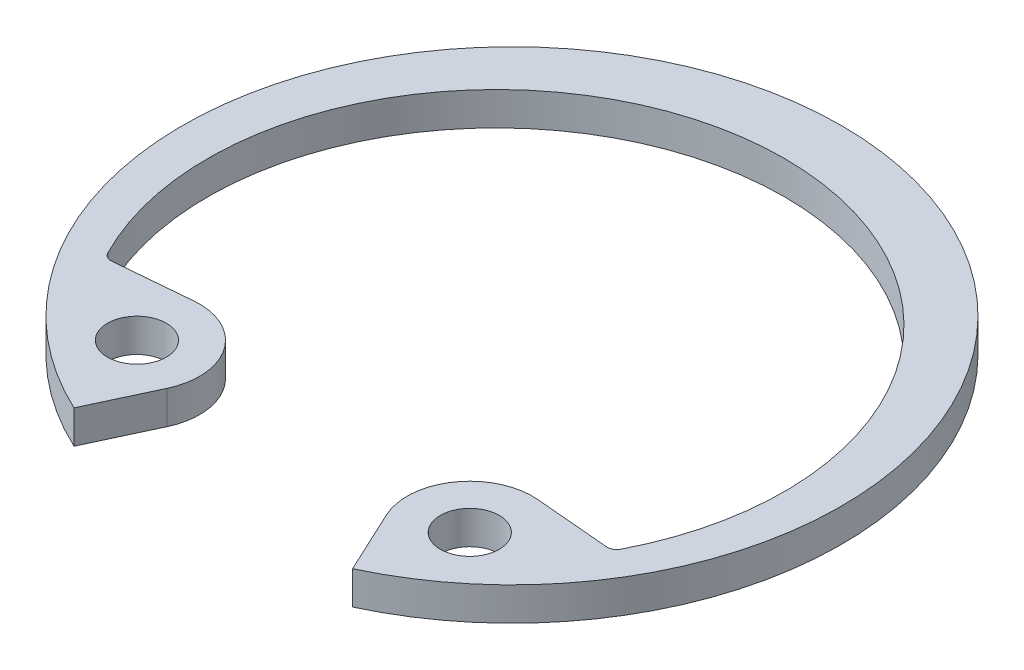
from build123d import *

# Parameters (mm, degrees)
SKETCH2_R      = 0.7874
EXTRUDE1_DEPTH = 0.889
FILLET1_R      = 0.254


with BuildPart() as part:
    # Sketch2 → Extrude1 (new body)
    with BuildSketch(Plane(origin=(0, 0, 0), x_dir=(1, 0, 0), z_dir=(0, 1, 0))):
        with BuildLine():
            Line((3.724872835, -7.988015573), (2.93201335, -6.28772292))
            ThreePointArc((2.93201335, -6.28772292), (3.078121237, -4.617702128), (4.597455611, -3.909224874))
            Line((4.597455611, -3.909224874), (6.781585425, -4.100311472))
            ThreePointArc((6.781585425, -4.100311472), (0, 7.2898), (-6.781585425, -4.100311472))
            Line((-6.781585425, -4.100311472), (-4.597455611, -3.909224874))
            ThreePointArc((-4.597455611, -3.909224874), (-3.078121237, -4.617702128), (-2.93201335, -6.28772292))
            Line((-2.93201335, -6.28772292), (-3.724872835, -7.988015573))
            ThreePointArc((-3.724872835, -7.988015573), (0, 8.8138), (3.724872835, -7.988015573))
        make_face()
        with Locations((4.451347724, -5.579245666)):
            Circle(SKETCH2_R, mode=Mode.SUBTRACT)
        with Locations((-4.451347724, -5.579245666)):
            Circle(SKETCH2_R, mode=Mode.SUBTRACT)
    extrude(amount=-EXTRUDE1_DEPTH)

    # Fillet1
    fillet1_edges = [part.edges().sort_by_distance(p)[0] for p in [
        (6.781585425, -0.4445, 4.100311472),
        (-6.781585425, -0.4445, 4.100311472),
    ]]
    fillet(fillet1_edges, radius=FILLET1_R)


solid = part.part
